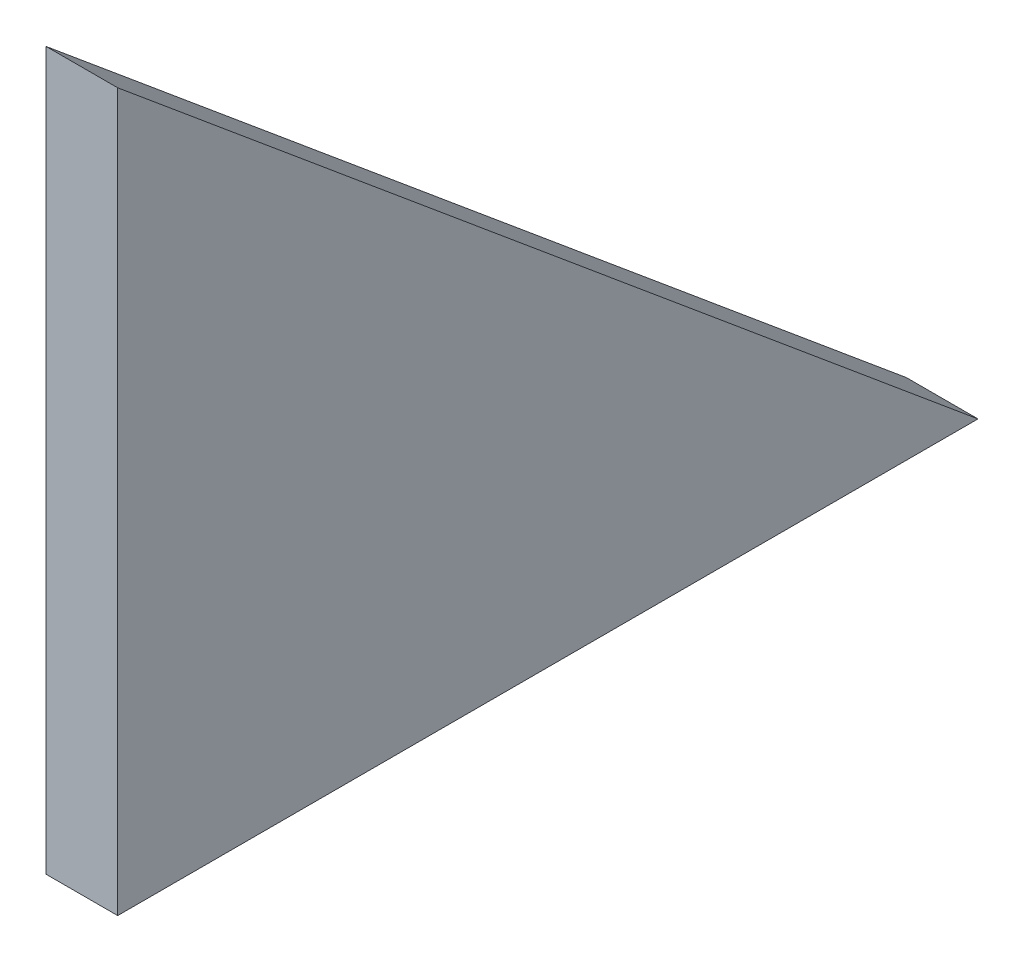
from build123d import *

# Parameters (mm, degrees)
EXTRUDE_1_DEPTH = 5


with BuildPart() as part:
    # Эскиз1 → Бобышка-Вытянуть1 (new body)
    with BuildSketch(Plane(origin=(0, 0, 0), x_dir=(0, 0, -1), z_dir=(1, 0, 0))):
        Polygon((0, 0), (60, 0), (0, 50), align=None)
    extrude(amount=EXTRUDE_1_DEPTH)


solid = part.part
